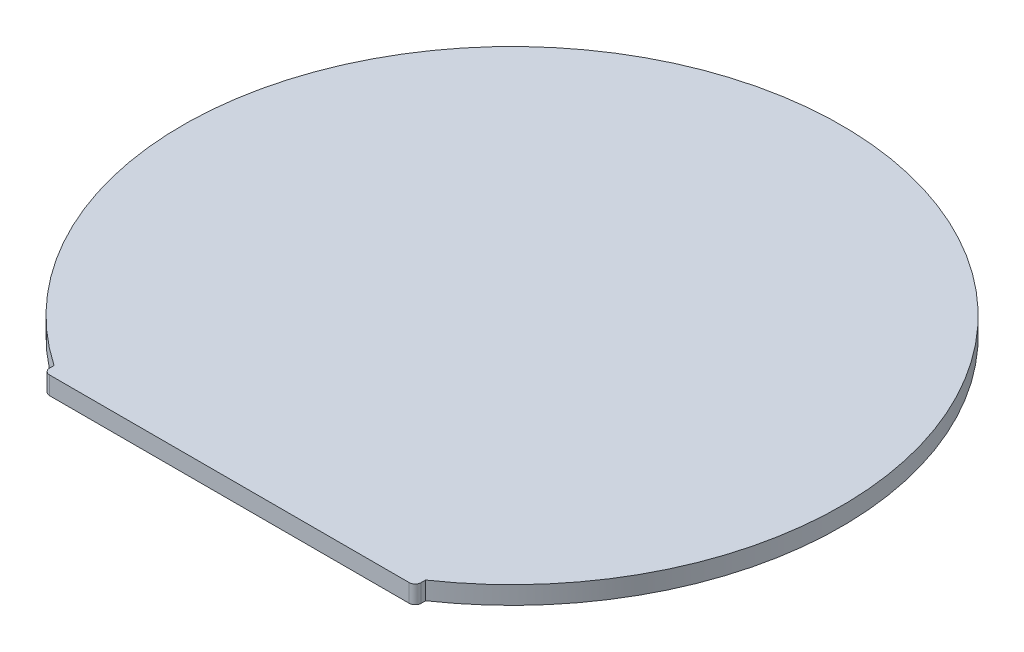
from build123d import *

# Parameters (mm, degrees)
BOSS_EXTRUDE1_DEPTH = 1.5
FILLET1_R           = 0.5


with BuildPart() as part:
    # Sketch1 → Boss-Extrude1 (new body)
    with BuildSketch(Plane(origin=(0, 0, 0), x_dir=(1, 0, 0), z_dir=(0, 1, 0))):
        with BuildLine():
            Line((-15.5, -23.58495283), (15.5, -23.58495283))
            Line((15.5, -23.58495283), (15.5, -22.715633383))
            ThreePointArc((15.5, -22.715633383), (0, 27.5), (-15.5, -22.715633383))
            Line((-15.5, -22.715633383), (-15.5, -23.58495283))
        make_face()
    extrude(amount=BOSS_EXTRUDE1_DEPTH)

    # Fillet1
    fillet1_edges = [part.edges().sort_by_distance(p)[0] for p in [
        (15.5, 0.75, 23.58495283),
        (-15.5, 0.75, 23.58495283),
    ]]
    fillet(fillet1_edges, radius=FILLET1_R)


solid = part.part
